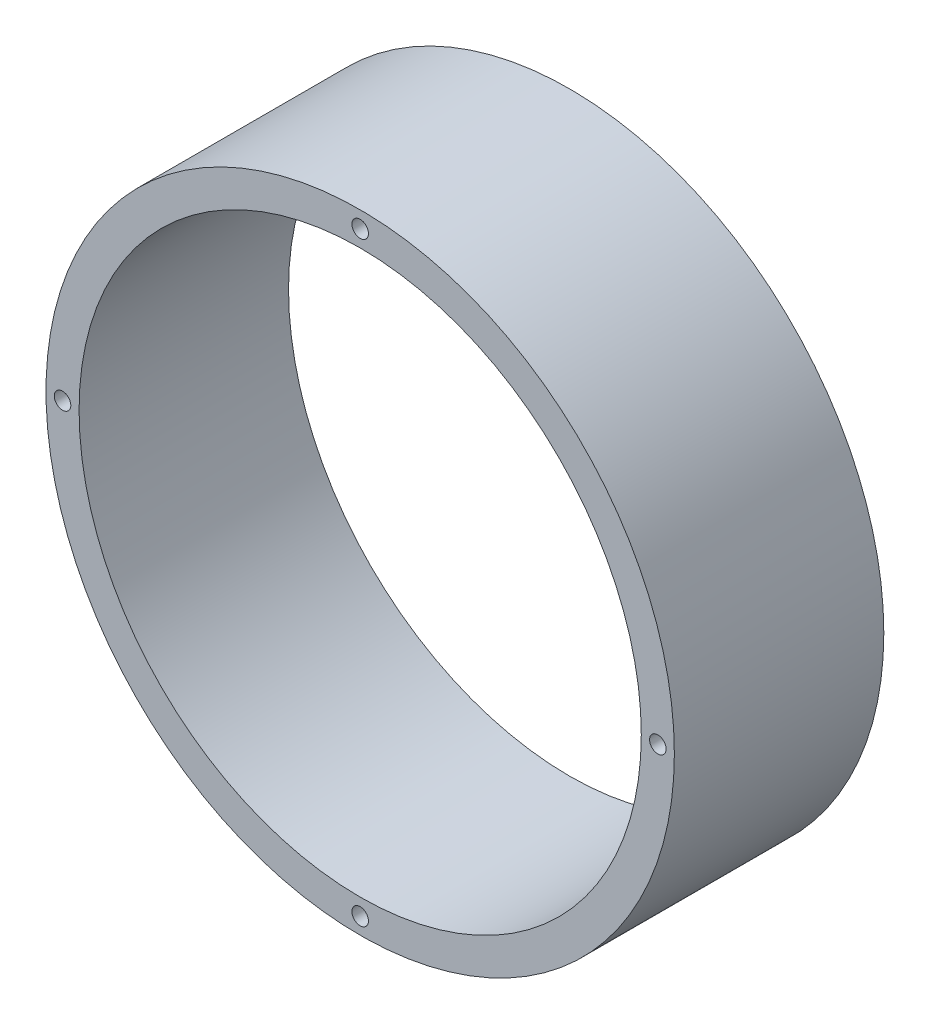
from build123d import *

# Parameters (mm, degrees)
SKETCH1_R           = 57
BOSS_EXTRUDE1_DEPTH = 38
SKETCH2_R           = 51
CUT_EXTRUDE1_DEPTH  = 39
SKETCH4_R           = 1.5
CUT_EXTRUDE3_DEPTH  = 15


with BuildPart() as part:
    # Sketch1 → Boss-Extrude1 (new body)
    with BuildSketch(Plane.XY):
        Circle(SKETCH1_R)
    extrude(amount=BOSS_EXTRUDE1_DEPTH)

    # Sketch2 → Cut-Extrude1 (cut)
    with BuildSketch(Plane.XY.offset(38)):
        Circle(SKETCH2_R)
    extrude(amount=-CUT_EXTRUDE1_DEPTH, mode=Mode.SUBTRACT)

    # Sketch4 → Cut-Extrude3 (cut)
    with BuildSketch(Plane(origin=(0, 0, 0), x_dir=(-1, 0, 0), z_dir=(0, 0, -1))):
        with Locations((0, 54)):
            Circle(SKETCH4_R)
        with Locations((54, 0)):
            Circle(SKETCH4_R)
        with Locations((0, -54)):
            Circle(SKETCH4_R)
        with Locations((-54, 0)):
            Circle(SKETCH4_R)
    cut_extrude3 = extrude(amount=-CUT_EXTRUDE3_DEPTH, mode=Mode.SUBTRACT)

    # Mirror1: Cut-Extrude3 across plane
    add(cut_extrude3.mirror(Plane.XY.offset(19)), mode=Mode.SUBTRACT)


solid = part.part
